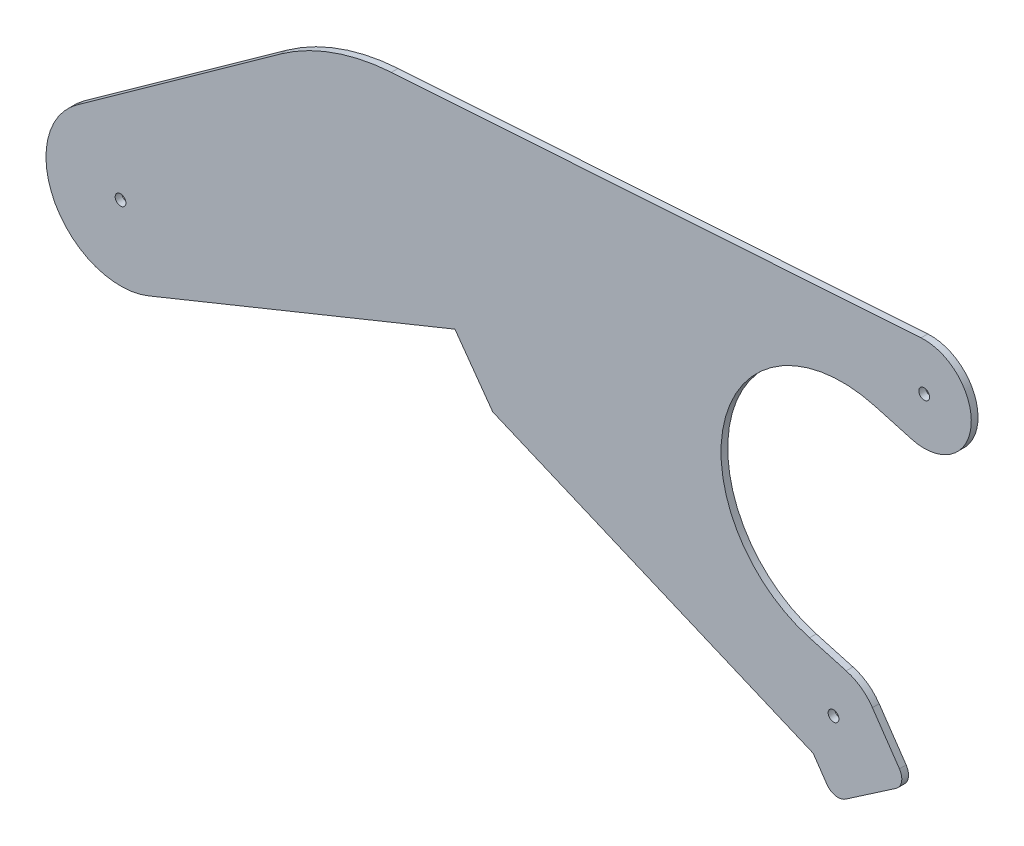
from build123d import *

# Parameters (mm, degrees)
SKETCH1_R           = 2.54
BOSS_EXTRUDE1_DEPTH = 3.175


with BuildPart() as part:
    # Sketch1 → Boss-Extrude1 (new body)
    with BuildSketch(Plane.XY):
        with BuildLine():
            Line((311.091686831, 197.898797126), (326.703198739, 191.301256821))
            Line((326.703198739, 191.301256821), (333.151451498, 181.876980863))
            ThreePointArc((333.151451498, 181.876980863), (337.221932682, 179.221504152), (341.977903119, 180.22206341))
            Line((341.977903119, 180.22206341), (365.723910723, 196.46949289))
            ThreePointArc((365.723910723, 196.46949289), (368.379387434, 200.539974074), (367.378828176, 205.295944512))
            Line((367.378828176, 205.295944512), (354.629507637, 223.929382055))
            ThreePointArc((354.629507637, 223.929382055), (349.230909811, 229.445982169), (342.271098909, 232.783461386))
            Line((342.271098909, 232.783461386), (324.973841412, 237.619253265))
            ThreePointArc((324.973841412, 237.619253265), (285.321700623, 308.046185122), (355.74863248, 347.698325911))
            Line((355.74863248, 347.698325911), (373.045889977, 342.862534033))
            ThreePointArc((373.045889977, 342.862534033), (401.136177569, 361.972870124), (377.568221423, 386.443682241))
            Line((377.568221423, 386.443682241), (127.710075685, 369.975787878))
            ThreePointArc((127.710075685, 369.975787878), (100.141013715, 364.248423846), (75.202698434, 351.174162585))
            Line((75.202698434, 351.174162585), (-20.489180282, 282.58567349))
            ThreePointArc((-20.489180282, 282.58567349), (-30.801832031, 237.023711212), (13.226628142, 221.411604128))
            Line((13.226628142, 221.411604128), (97.792658847, 255.734356495))
            Line((97.792658847, 255.734356495), (157.72015625, 280.057085564))
            Line((157.72015625, 280.057085564), (175.551948383, 255.17889226))
            Line((175.551948383, 255.17889226), (311.091686831, 197.898797126))
        make_face()
        with Locations((379.029877129, 364.266798159)):
            Circle(SKETCH1_R, mode=Mode.SUBTRACT)
        with Locations((336.287111757, 211.37919726)):
            Circle(SKETCH1_R, mode=Mode.SUBTRACT)
        with Locations((0, 254)):
            Circle(SKETCH1_R, mode=Mode.SUBTRACT)
    extrude(amount=BOSS_EXTRUDE1_DEPTH)


solid = part.part
